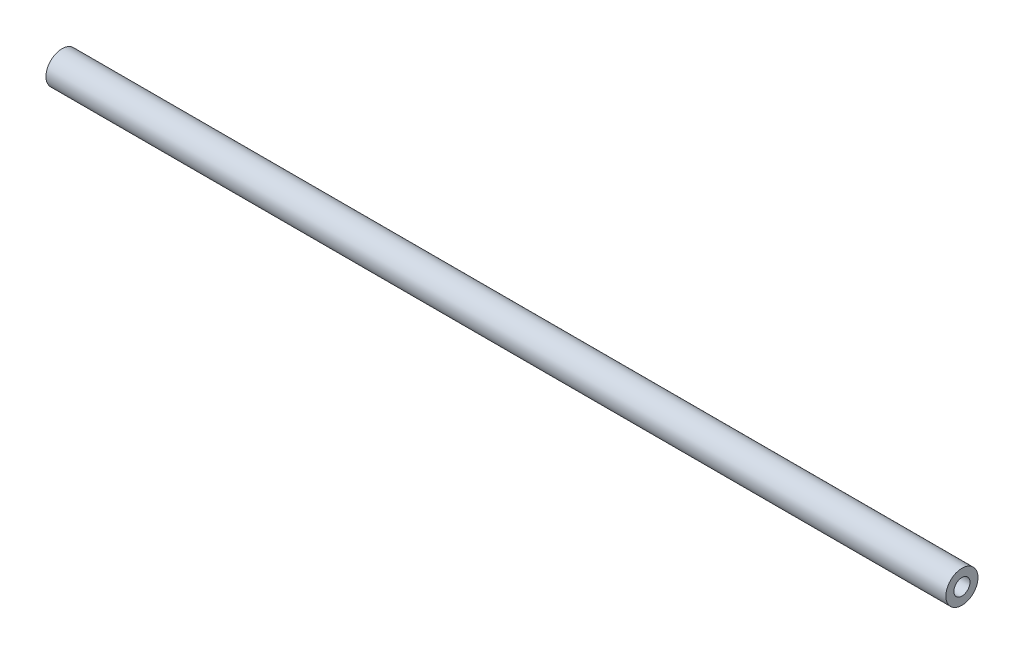
from build123d import *

# Parameters (mm, degrees)
SKETCH1_R           = 6.35
SKETCH1_R_2         = 3.175
BOSS_EXTRUDE1_DEPTH = 355.6


with BuildPart() as part:
    # Sketch1 → Boss-Extrude1 (new body)
    with BuildSketch(Plane(origin=(0, 0, 0), x_dir=(0, 0, -1), z_dir=(1, 0, 0))):
        Circle(SKETCH1_R)
        Circle(SKETCH1_R_2, mode=Mode.SUBTRACT)
    extrude(amount=BOSS_EXTRUDE1_DEPTH)


solid = part.part
